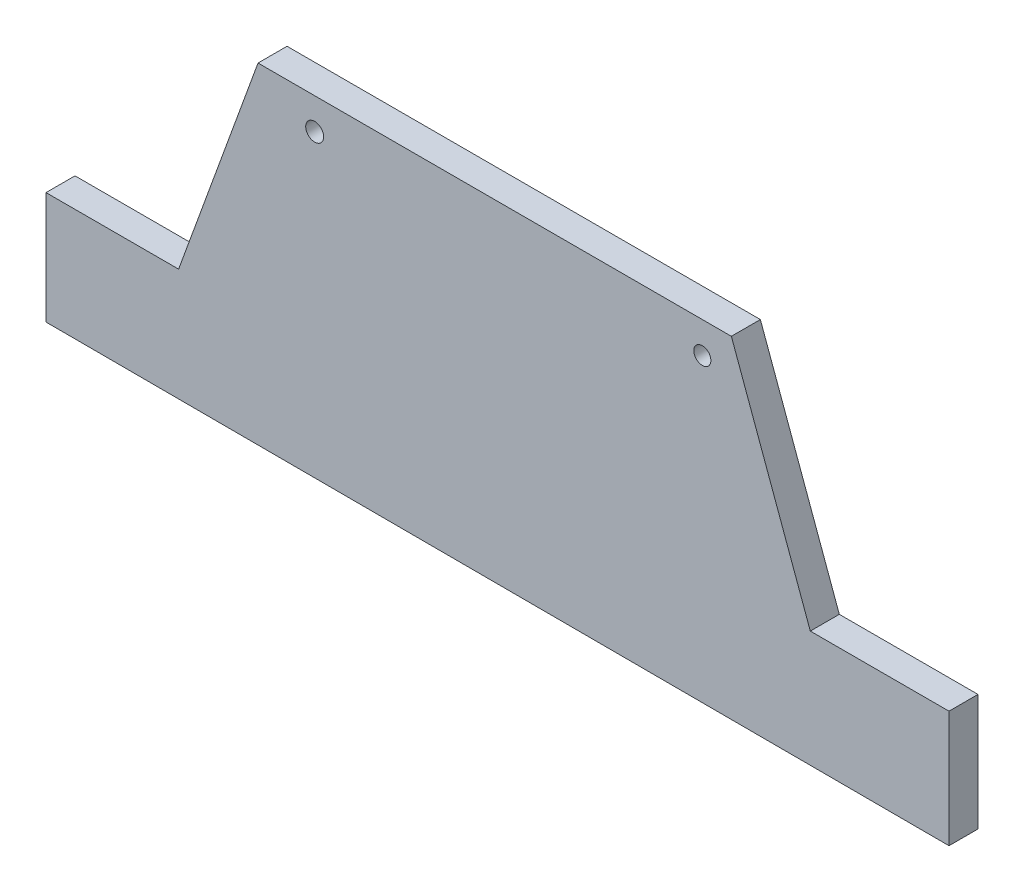
from build123d import *

# Parameters (mm, degrees)
SKETCH1_R                = 3.817508494
SKETCH1_R_2              = 4
BOSS_EXTRUDE1_DEPTH      = 12.933846798
BOSS_EXTRUDE1_DEPTH_BACK = 0.0001


with BuildPart() as part:
    # Sketch1 → Boss-Extrude1 (new body, two sides)
    with BuildSketch(Plane.XY) as boss_extrude1_sk:
        Polygon((171.212226028, 51.069530268), (136.012624897, 147.29914138), (-75.017990846, 147.29914138), (-110.431982128, 50), (-169.555830253, 50), (-169.555830253, 0), (233.044157252, -0.895163773), (233.044157252, 51.069530268), align=None)
        with Locations((123.066759463, 133.392636667)):
            Circle(SKETCH1_R, mode=Mode.SUBTRACT)
        with Locations((-49.767828392, 133.392636667)):
            Circle(SKETCH1_R_2, mode=Mode.SUBTRACT)
    extrude(amount=BOSS_EXTRUDE1_DEPTH)
    extrude(boss_extrude1_sk.sketch, amount=-BOSS_EXTRUDE1_DEPTH_BACK)


solid = part.part
